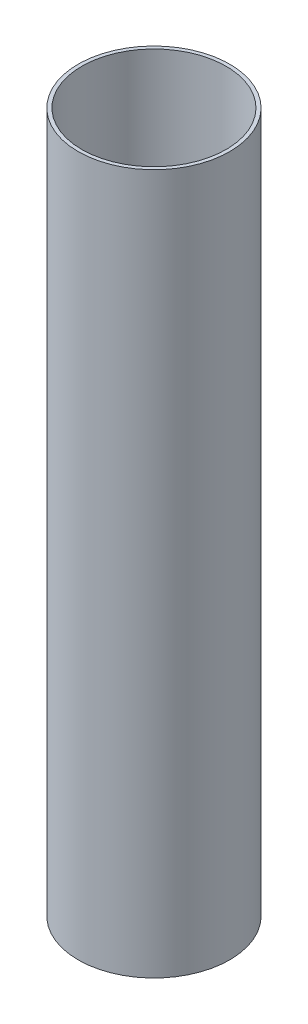
from build123d import *

# Parameters (mm, degrees)
SKETCH1_R           = 21
SKETCH1_R_2         = 20
BOSS_EXTRUDE2_DEPTH = 194


with BuildPart() as part:
    # Sketch1 → Boss-Extrude2 (new body)
    with BuildSketch(Plane(origin=(0, 0, 0), x_dir=(1, 0, 0), z_dir=(0, 1, 0))):
        Circle(SKETCH1_R)
        Circle(SKETCH1_R_2, mode=Mode.SUBTRACT)
    extrude(amount=BOSS_EXTRUDE2_DEPTH)


solid = part.part
